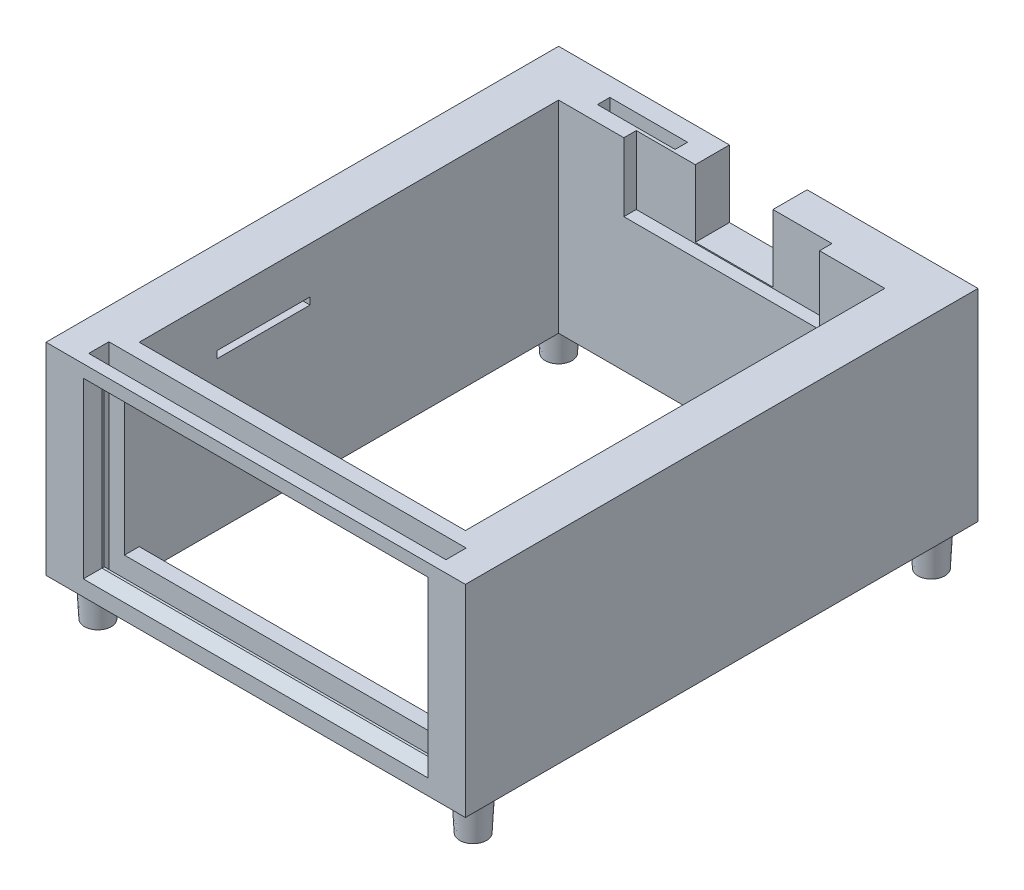
from build123d import *

# Parameters (mm, degrees)
SKETCH1_W           = 135
SKETCH1_H           = 165
BOSS_EXTRUDE1_DEPTH = 65
SKETCH2_W           = 105
SKETCH2_H           = 135
CUT_EXTRUDE1_DEPTH  = 66
SKETCH3_W           = 30
SKETCH3_H           = 2.27229553
CUT_EXTRUDE2_DEPTH  = 12
SKETCH4_W           = 25
SKETCH4_H           = 4
CUT_EXTRUDE3_DEPTH  = 66
SKETCH5_W           = 115
SKETCH5_H           = 6.5
CUT_EXTRUDE4_DEPTH  = 66
SKETCH7_R           = 5
BOSS_EXTRUDE2_DEPTH = 13
BOSS_EXTRUDE2_TAPER = 3
SKETCH8_R           = 5
BOSS_EXTRUDE3_DEPTH = 13
BOSS_EXTRUDE3_TAPER = 3
SKETCH9_R           = 5
BOSS_EXTRUDE4_DEPTH = 13
BOSS_EXTRUDE4_TAPER = 3
SKETCH10_W          = 105
SKETCH10_H          = 49.956638738
CUT_EXTRUDE5_DEPTH  = 15
CHAMFER3_SIZE       = 3
SKETCH14_W          = 63
SKETCH14_H          = 22
CUT_EXTRUDE6_DEPTH  = 4
SKETCH15_W          = 25
SKETCH15_H          = 25
CUT_EXTRUDE7_DEPTH  = 13


with BuildPart() as part:
    # Sketch1 → Boss-Extrude1 (new body)
    with BuildSketch(Plane(origin=(0, 0, 0), x_dir=(1, 0, 0), z_dir=(0, 1, 0))):
        Rectangle(SKETCH1_W, SKETCH1_H)
    extrude(amount=BOSS_EXTRUDE1_DEPTH)

    # Sketch2 → Cut-Extrude1 (cut, through all)
    with BuildSketch(Plane(origin=(0, 65, 0), x_dir=(1, 0, 0), z_dir=(0, 1, 0))):
        Rectangle(SKETCH2_W, SKETCH2_H)
    extrude(amount=-CUT_EXTRUDE1_DEPTH, mode=Mode.SUBTRACT)

    # Sketch3 → Cut-Extrude2 (cut)
    with BuildSketch(Plane(origin=(-52.5, 0, 0), x_dir=(0, 0, -1), z_dir=(1, 0, 0))):
        with Locations((-27.5, 49)):
            Rectangle(SKETCH3_W, SKETCH3_H)
    extrude(amount=-CUT_EXTRUDE2_DEPTH, mode=Mode.SUBTRACT)

    # Sketch4 → Cut-Extrude3 (cut, through all)
    with BuildSketch(Plane(origin=(0, 65, 0), x_dir=(1, 0, 0), z_dir=(0, 1, 0))):
        with Locations((-32.5, 74.5)):
            Rectangle(SKETCH4_W, SKETCH4_H)
    extrude(amount=-CUT_EXTRUDE3_DEPTH, mode=Mode.SUBTRACT)

    # Sketch5 → Cut-Extrude4 (cut, through all)
    with BuildSketch(Plane(origin=(0, 65, 0), x_dir=(1, 0, 0), z_dir=(0, 1, 0))):
        with Locations((0, -75.5)):
            Rectangle(SKETCH5_W, SKETCH5_H)
    extrude(amount=-CUT_EXTRUDE4_DEPTH, mode=Mode.SUBTRACT)

    # Sketch7 → Boss-Extrude2 (add)
    with BuildSketch(Plane.XZ):
        with Locations((-60, -75)):
            Circle(SKETCH7_R)
    extrude(amount=BOSS_EXTRUDE2_DEPTH, taper=BOSS_EXTRUDE2_TAPER)

    # Sketch8 → Boss-Extrude3 (add)
    with BuildSketch(Plane.XZ):
        with Locations((60, -75)):
            Circle(SKETCH8_R)
    extrude(amount=BOSS_EXTRUDE3_DEPTH, taper=BOSS_EXTRUDE3_TAPER)

    # Sketch9 → Boss-Extrude4 (add)
    with BuildSketch(Plane.XZ):
        with Locations((60, 72.5)):
            Circle(SKETCH9_R)
        with Locations((-60, 73.301994408)):
            Circle(SKETCH9_R)
    extrude(amount=BOSS_EXTRUDE4_DEPTH, taper=BOSS_EXTRUDE4_TAPER)

    # Sketch10 → Cut-Extrude5 (cut)
    with BuildSketch(Plane.XY.offset(82.5)):
        with Locations((0, 33)):
            Rectangle(SKETCH10_W, SKETCH10_H)
    extrude(amount=-CUT_EXTRUDE5_DEPTH, mode=Mode.SUBTRACT)

    # Chamfer3
    chamfer3_edges = [part.edges().sort_by_distance(p)[0] for p in [
        (52.5, 33, 82.5),
        (0, 57.978319369, 82.5),
        (-52.5, 33, 82.5),
        (0, 8.021680631, 82.5),
    ]]
    chamfer(chamfer3_edges, length=CHAMFER3_SIZE)

    # Sketch14 → Cut-Extrude6 (cut)
    with BuildSketch(Plane.XY.offset(-67.5)):
        with Locations((0, 54)):
            Rectangle(SKETCH14_W, SKETCH14_H)
    extrude(amount=-CUT_EXTRUDE6_DEPTH, mode=Mode.SUBTRACT)

    # Sketch15 → Cut-Extrude7 (cut)
    with BuildSketch(Plane.XY.offset(-71.5)):
        with Locations((0, 55.862062237)):
            Rectangle(SKETCH15_W, SKETCH15_H)
    extrude(amount=-CUT_EXTRUDE7_DEPTH, mode=Mode.SUBTRACT)


solid = part.part
